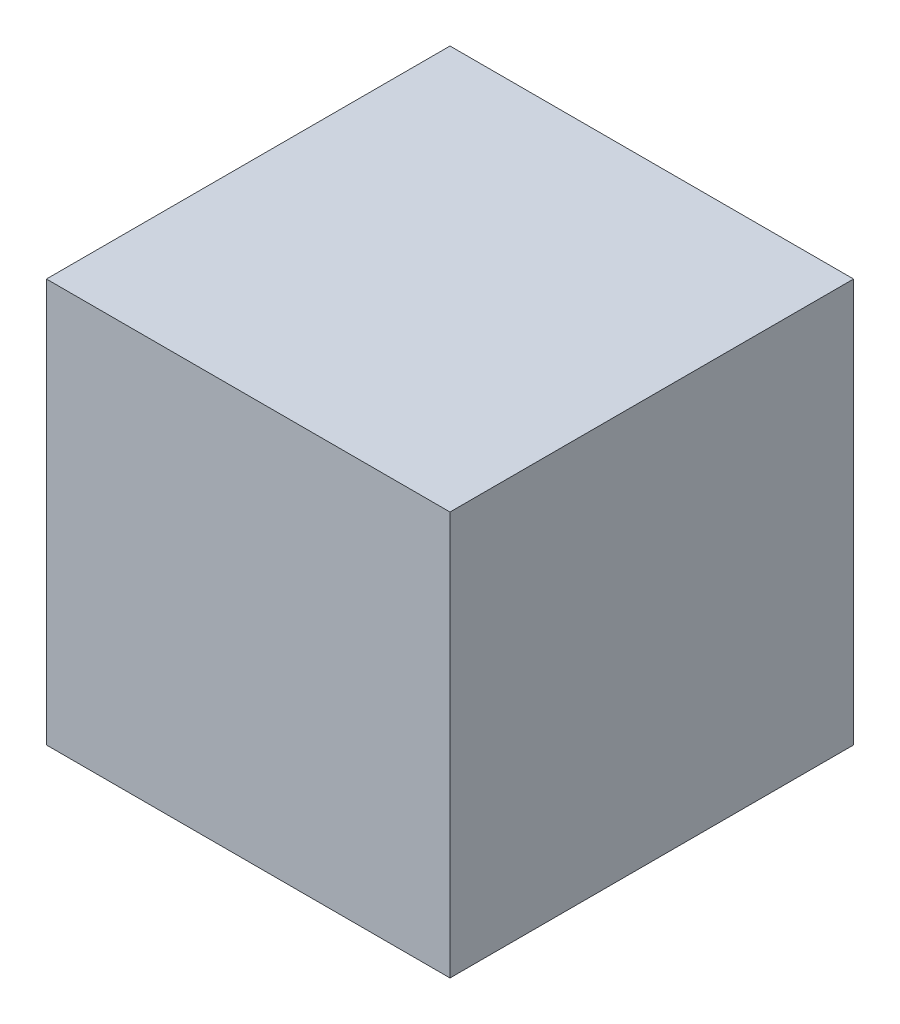
from build123d import *

# Parameters (mm, degrees)
SKETCH_1_W      = 40
SKETCH_1_H      = 40
EXTRUDE_1_DEPTH = 40


with BuildPart() as part:
    # 草图1 → 凸台-拉伸1 (new body)
    with BuildSketch(Plane(origin=(0, 0, 0), x_dir=(0, 0, -1), z_dir=(1, 0, 0))):
        with Locations((20, 20)):
            Rectangle(SKETCH_1_W, SKETCH_1_H)
    extrude(amount=EXTRUDE_1_DEPTH)


solid = part.part
